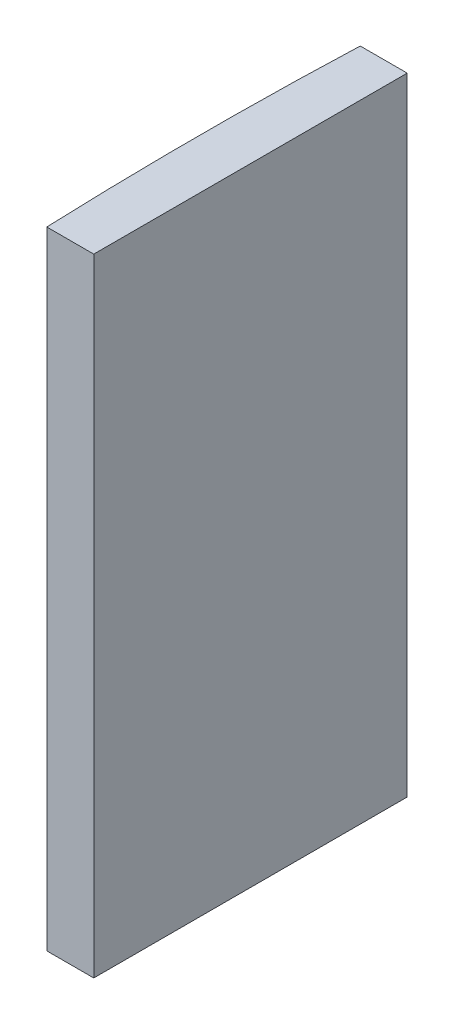
from build123d import *

# Parameters (mm, degrees)
EXTRUDE_1_DEPTH = 40


with BuildPart() as part:
    # 草图1 → 凸台-拉伸1 (new body)
    with BuildSketch(Plane(origin=(0, 0, 0), x_dir=(1, 0, 0), z_dir=(0, 1, 0))):
        with BuildLine():
            Line((-253.951299648, 10), (-250.954795665, 10))
            Line((-250.954795665, 10), (-250.954795665, -10))
            Line((-250.954795665, -10), (-253.951299648, -10))
            ThreePointArc((-253.951299648, -10), (-254.144795665, 0), (-253.951299648, 10))
        make_face()
    extrude(amount=EXTRUDE_1_DEPTH)


solid = part.part
